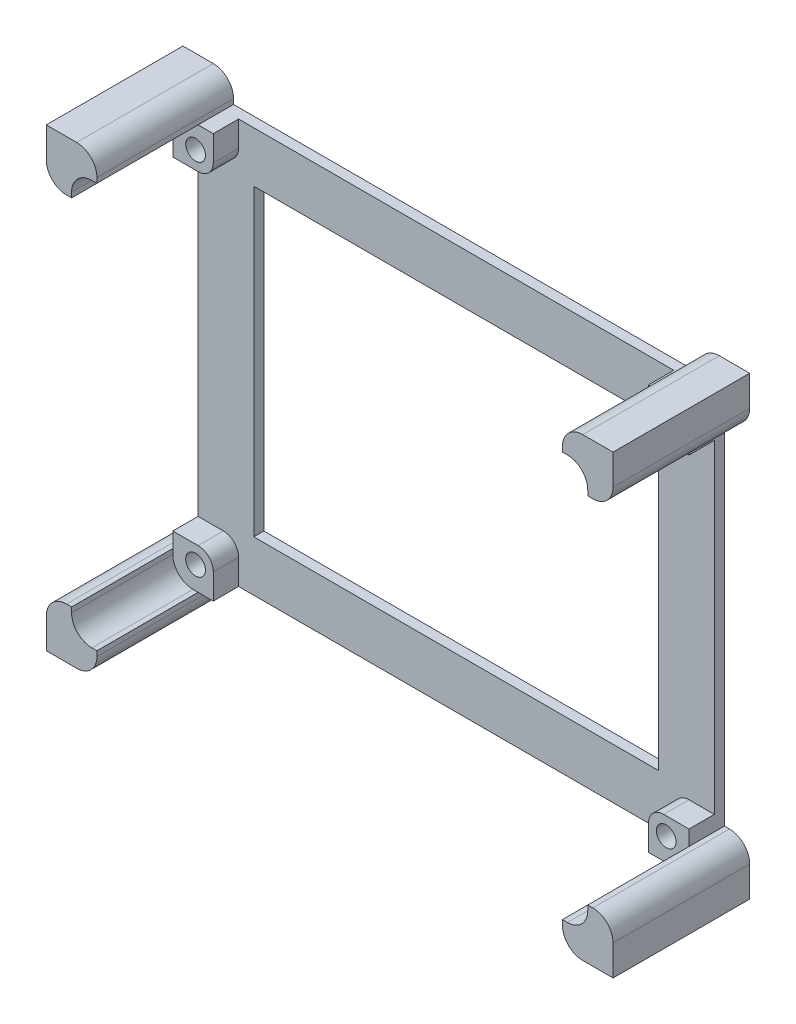
from build123d import *

# Parameters (mm, degrees)
BOSS_EXTRUDE2_DEPTH = 27
SKETCH3_W           = 102
SKETCH3_H           = 80
CUT_EXTRUDE2_DEPTH  = 25
SKETCH4_W           = 8
SKETCH4_H           = 8
BOSS_EXTRUDE3_DEPTH = 5
SKETCH7_R           = 1.95
CUT_EXTRUDE3_DEPTH  = 3
FILLET2_R           = 3
FILLET3_R           = 4
SKETCH8_W           = 80
SKETCH8_H           = 60
CUT_EXTRUDE4_DEPTH  = 3


with BuildPart() as part:
    # Sketch1 → Boss-Extrude2 (new body)
    with BuildSketch(Plane.XY):
        Polygon((0, 75), (-5, 75), (-5, 85), (5, 85), (5, 80), (97, 80), (97, 85), (107, 85), (107, 75), (102, 75), (102, 5), (107, 5), (107, -5), (97, -5), (97, 0), (5, 0), (5, -5), (-5, -5), (-5, 5), (0, 5), align=None)
    extrude(amount=BOSS_EXTRUDE2_DEPTH)

    # Sketch3 → Cut-Extrude2 (cut)
    with BuildSketch(Plane.XY.offset(27)):
        with Locations((51, 40)):
            Rectangle(SKETCH3_W, SKETCH3_H)
    extrude(amount=-CUT_EXTRUDE2_DEPTH, mode=Mode.SUBTRACT)

    # Sketch4 → Boss-Extrude3 (add)
    with BuildSketch(Plane.XY.offset(2)):
        with Locations((4, 76)):
            Rectangle(SKETCH4_W, SKETCH4_H)
        with Locations((98, 76)):
            Rectangle(SKETCH4_W, SKETCH4_H)
        with Locations((98, 4)):
            Rectangle(SKETCH4_W, SKETCH4_H)
        with Locations((4, 4)):
            Rectangle(SKETCH4_W, SKETCH4_H)
    extrude(amount=BOSS_EXTRUDE3_DEPTH)

    # Sketch7 → Cut-Extrude3 (cut)
    with BuildSketch(Plane.XY.offset(7)):
        with Locations((4.5, 75.5)):
            Circle(SKETCH7_R)
        with Locations((97.5, 75.5)):
            Circle(SKETCH7_R)
        with Locations((97.5, 4.5)):
            Circle(SKETCH7_R)
        with Locations((4.5, 4.5)):
            Circle(SKETCH7_R)
    extrude(amount=-CUT_EXTRUDE3_DEPTH, mode=Mode.SUBTRACT)

    # Fillet2
    fillet2_edges = [part.edges().sort_by_distance(p)[0] for p in [
        (94, 72, 4.5),
        (94, 8, 4.5),
        (8, 8, 4.5),
        (8, 72, 4.5),
    ]]
    fillet(fillet2_edges, radius=FILLET2_R)

    # Fillet3
    fillet3_edges = [part.edges().sort_by_distance(p)[0] for p in [
        (102, 80, 17),
        (102, 0, 17),
        (0, 0, 17),
        (-5, 75, 13.5),
        (5, 85, 13.5),
        (97, 85, 13.5),
        (107, 75, 13.5),
        (107, 5, 13.5),
        (97, -5, 13.5),
        (5, -5, 13.5),
        (-5, 5, 13.5),
        (0, 80, 17),
    ]]
    fillet(fillet3_edges, radius=FILLET3_R)

    # Sketch8 → Cut-Extrude4 (cut, through all)
    with BuildSketch(Plane.XY.offset(2)):
        with Locations((51, 40)):
            Rectangle(SKETCH8_W, SKETCH8_H)
    extrude(amount=-CUT_EXTRUDE4_DEPTH, mode=Mode.SUBTRACT)


solid = part.part
